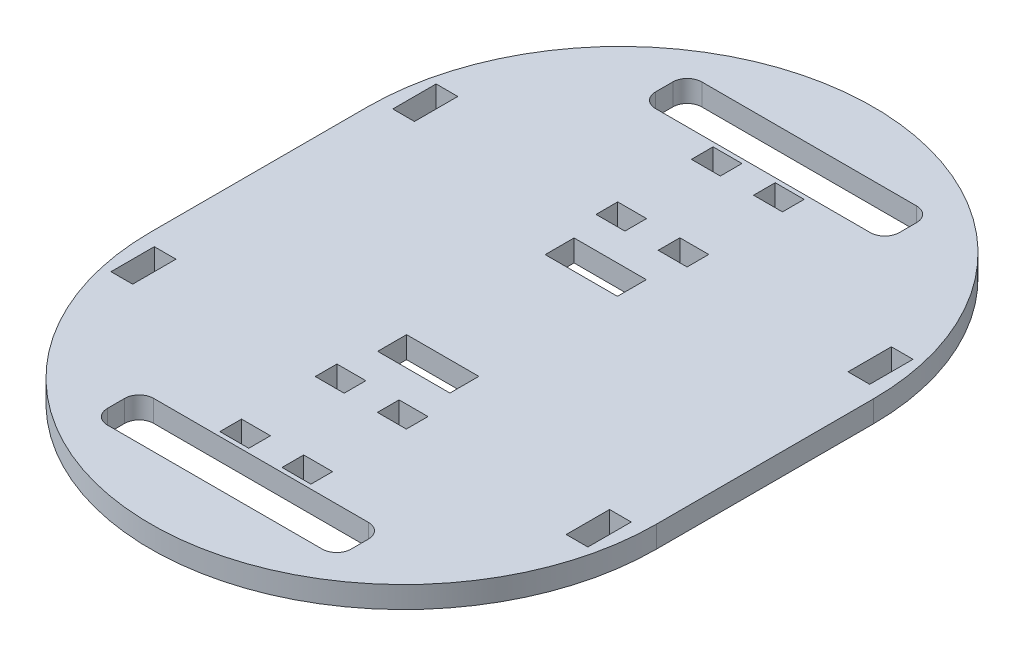
from build123d import *

# Parameters (mm, degrees)
BOSS_EXTRUDE1_DEPTH     = 7.62
SKETCH2_W               = 85.677392152
SKETCH2_H               = 16.256
CUT_EXTRUDE1_DEPTH      = 1
CUT_EXTRUDE1_DEPTH_BACK = 8.62
FILLET1_R               = 5.08
SKETCH3_W               = 10.16
SKETCH3_H               = 7.62
CUT_EXTRUDE2_DEPTH      = 8.62
SKETCH4_W               = 25.4
SKETCH4_H               = 10.16
CUT_EXTRUDE3_DEPTH      = 8.62
SKETCH5_W               = 7.62
SKETCH5_H               = 15.24
CUT_EXTRUDE5_DEPTH      = 8.62


with BuildPart() as part:
    # Sketch1 → Boss-Extrude1 (new body)
    with BuildSketch(Plane(origin=(0, 0, 0), x_dir=(1, 0, 0), z_dir=(0, 1, 0))):
        with BuildLine():
            Line((-88.9, 0), (-88.9, 76.2))
            ThreePointArc((-88.9, 76.2), (0, 165.1), (88.9, 76.2))
            Line((88.9, 76.2), (88.9, 0))
            ThreePointArc((88.9, 0), (0, -88.9), (-88.9, 0))
        make_face()
    extrude(amount=BOSS_EXTRUDE1_DEPTH)

    # Sketch2 → Cut-Extrude1 (cut, two sides)
    with BuildSketch(Plane(origin=(0, 7.62, 0), x_dir=(1, 0, 0), z_dir=(0, 1, 0))) as cut_extrude1_sk:
        with Locations((0, -58.235236409)):
            Rectangle(SKETCH2_W, SKETCH2_H)
        with Locations((0, 134.435236409)):
            Rectangle(SKETCH2_W, SKETCH2_H)
    extrude(amount=CUT_EXTRUDE1_DEPTH, mode=Mode.SUBTRACT)
    extrude(cut_extrude1_sk.sketch, amount=-CUT_EXTRUDE1_DEPTH_BACK, mode=Mode.SUBTRACT)

    # Fillet1
    fillet1_edges = [part.edges().sort_by_distance(p)[0] for p in [
        (-42.838696076, 3.81, 66.363236409),
        (-42.838696076, 3.81, 50.107236409),
        (42.838696076, 3.81, 50.107236409),
        (42.838696076, 3.81, 66.363236409),
        (-42.838696076, 3.81, -126.307236409),
        (-42.838696076, 3.81, -142.563236409),
        (42.838696076, 3.81, -142.563236409),
        (42.838696076, 3.81, -126.307236409),
    ]]
    fillet(fillet1_edges, radius=FILLET1_R)

    # Sketch3 → Cut-Extrude2 (cut, through all)
    with BuildSketch(Plane(origin=(0, 7.62, 0), x_dir=(1, 0, 0), z_dir=(0, 1, 0))):
        with Locations((10.922, 87.445236409)):
            Rectangle(SKETCH3_W, SKETCH3_H)
        with Locations((-10.922, 87.445236409)):
            Rectangle(SKETCH3_W, SKETCH3_H)
        with Locations((10.922, 120.973236409)):
            Rectangle(SKETCH3_W, SKETCH3_H)
        with Locations((-10.922, 120.973236409)):
            Rectangle(SKETCH3_W, SKETCH3_H)
        with Locations((-10.922, -11.245236409)):
            Rectangle(SKETCH3_W, SKETCH3_H)
        with Locations((10.922, -11.245236409)):
            Rectangle(SKETCH3_W, SKETCH3_H)
        with Locations((-10.922, -44.773236409)):
            Rectangle(SKETCH3_W, SKETCH3_H)
        with Locations((10.922, -44.773236409)):
            Rectangle(SKETCH3_W, SKETCH3_H)
    extrude(amount=-CUT_EXTRUDE2_DEPTH, mode=Mode.SUBTRACT)

    # Sketch4 → Cut-Extrude3 (cut, through all)
    with BuildSketch(Plane(origin=(0, 7.62, 0), x_dir=(1, 0, 0), z_dir=(0, 1, 0))):
        with Locations((0, 67.537940424)):
            Rectangle(SKETCH4_W, SKETCH4_H)
        with Locations((0, 8.662059576)):
            Rectangle(SKETCH4_W, SKETCH4_H)
    extrude(amount=-CUT_EXTRUDE3_DEPTH, mode=Mode.SUBTRACT)

    # Sketch5 → Cut-Extrude5 (cut, through all)
    with BuildSketch(Plane(origin=(0, 7.62, 0), x_dir=(1, 0, 0), z_dir=(0, 1, 0))):
        with Locations((80.01, -11.43)):
            Rectangle(SKETCH5_W, SKETCH5_H)
        with Locations((-80.01, -11.43)):
            Rectangle(SKETCH5_W, SKETCH5_H)
        with Locations((-80.01, 87.63)):
            Rectangle(SKETCH5_W, SKETCH5_H)
        with Locations((80.01, 87.63)):
            Rectangle(SKETCH5_W, SKETCH5_H)
    extrude(amount=-CUT_EXTRUDE5_DEPTH, mode=Mode.SUBTRACT)


solid = part.part
